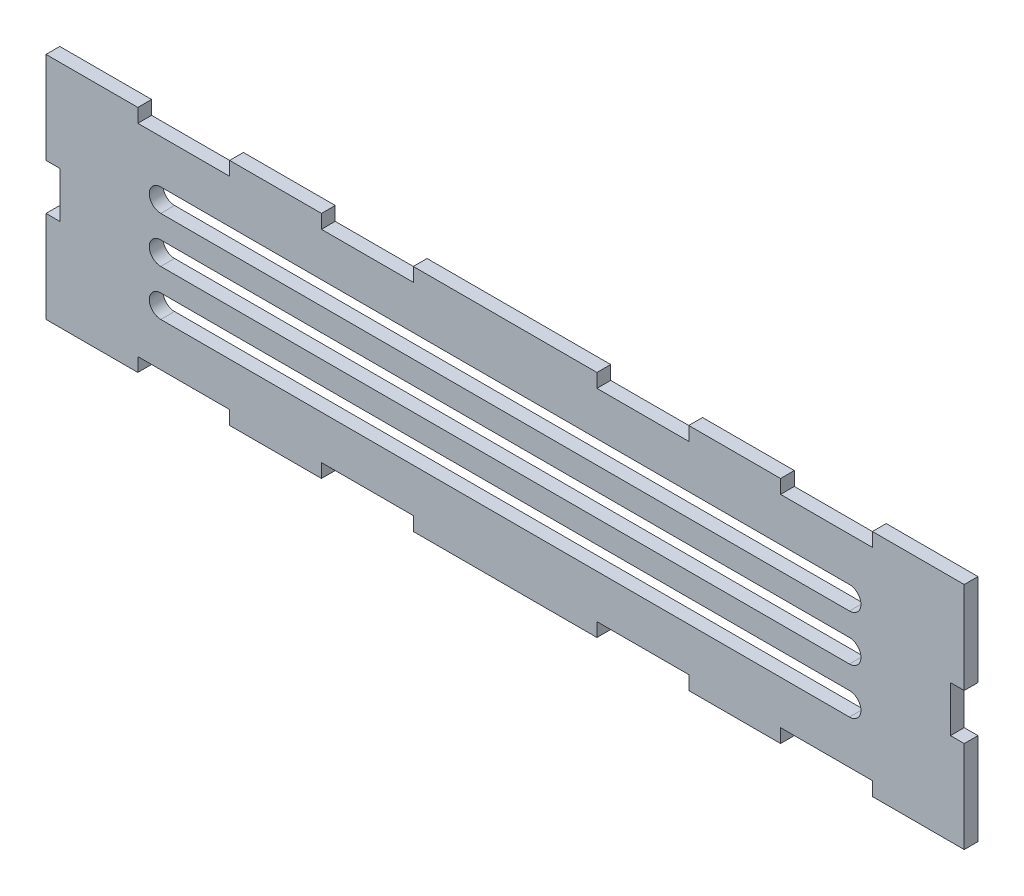
from build123d import *

# Parameters (mm, degrees)
SKETCH1_W           = 200
SKETCH1_H           = 50
BOSS_EXTRUDE1_DEPTH = 3
SKETCH2_W           = 20
SKETCH2_H           = 3
SKETCH2_W_2         = 3
SKETCH2_H_2         = 10
CUT_EXTRUDE1_DEPTH  = 3
CUT_EXTRUDE2_DEPTH  = 3


with BuildPart() as part:
    # Sketch1 → Boss-Extrude1 (new body)
    with BuildSketch(Plane.XY):
        Rectangle(SKETCH1_W, SKETCH1_H)
    extrude(amount=BOSS_EXTRUDE1_DEPTH)

    # Sketch2 → Cut-Extrude1 (cut)
    with BuildSketch(Plane.XY.offset(3)):
        with Locations((-70, 23.5)):
            Rectangle(SKETCH2_W, SKETCH2_H)
        with Locations((-30, -23.5)):
            Rectangle(SKETCH2_W, SKETCH2_H)
        with Locations((98.5, 0)):
            Rectangle(SKETCH2_W_2, SKETCH2_H_2)
        with Locations((-70, -23.5)):
            Rectangle(SKETCH2_W, SKETCH2_H)
        with Locations((30, 23.5)):
            Rectangle(SKETCH2_W, SKETCH2_H)
        with Locations((70, 23.5)):
            Rectangle(SKETCH2_W, SKETCH2_H)
        with Locations((-30, 23.5)):
            Rectangle(SKETCH2_W, SKETCH2_H)
        with Locations((30, -23.5)):
            Rectangle(SKETCH2_W, SKETCH2_H)
        with Locations((70, -23.5)):
            Rectangle(SKETCH2_W, SKETCH2_H)
        with Locations((-98.5, 0)):
            Rectangle(SKETCH2_W_2, SKETCH2_H_2)
    extrude(amount=-CUT_EXTRUDE1_DEPTH, mode=Mode.SUBTRACT)

    # Sketch3 → Cut-Extrude2 (cut)
    with BuildSketch(Plane.XY.offset(3)):
        with BuildLine():
            Line((75, 7.5), (-75, 7.5))
            ThreePointArc((-75, 7.5), (-77.5, 10), (-75, 12.5))
            Line((-75, 12.5), (75, 12.5))
            ThreePointArc((75, 12.5), (77.5, 10), (75, 7.5))
        make_face()
        with BuildLine():
            Line((75, -2.5), (-75, -2.5))
            ThreePointArc((-75, -2.5), (-77.5, 0), (-75, 2.5))
            Line((-75, 2.5), (75, 2.5))
            ThreePointArc((75, 2.5), (77.5, 0), (75, -2.5))
        make_face()
        with BuildLine():
            Line((75, -12.5), (-75, -12.5))
            ThreePointArc((-75, -12.5), (-77.5, -10), (-75, -7.5))
            Line((-75, -7.5), (75, -7.5))
            ThreePointArc((75, -7.5), (77.5, -10), (75, -12.5))
        make_face()
    extrude(amount=-CUT_EXTRUDE2_DEPTH, mode=Mode.SUBTRACT)


solid = part.part
